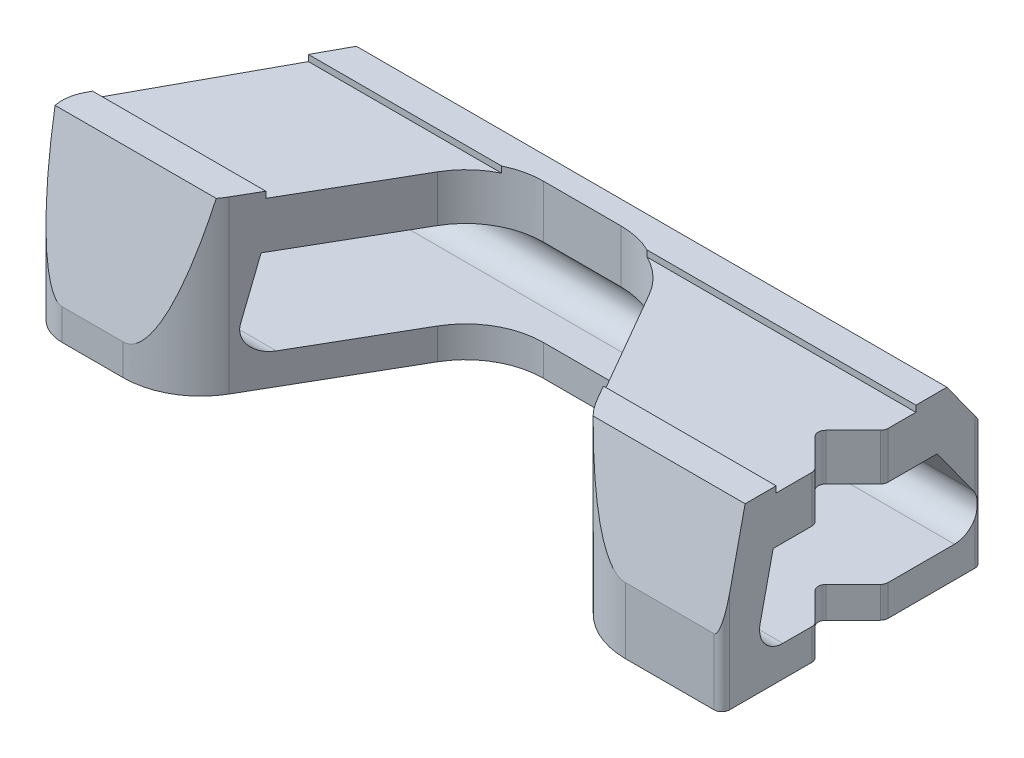
from build123d import *

# Parameters (mm, degrees)
SKETCH1_R               = 5
BOSS_EXTRUDE1_DEPTH     = 22
FILLET1_R               = 1
FILLET2_R               = 10
SKETCH3_W               = 18
SKETCH3_H               = 10
CUT_EXTRUDE2_DEPTH      = 45
CUT_EXTRUDE2_DEPTH_BACK = 46


with BuildPart() as part:
    # Sketch1 → Boss-Extrude1 (new body)
    with BuildSketch(Plane(origin=(0, 0, 0), x_dir=(1, 0, 0), z_dir=(0, 1, 0))):
        with BuildLine():
            Line((44, 17), (35, 26))
            Line((35, 26), (25, 26))
            Line((25, 26), (5, 20.641016151))
            Line((5, 20.641016151), (-15, 26))
            Line((-15, 26), (-25, 26))
            Line((-25, 26), (-44.391127187, -9.608765584))
            ThreePointArc((-44.391127187, -9.608765584), (-38.766232585, -7.154608585), (-35, -12))
            ThreePointArc((-35, -12), (-36.464466094, -15.535533906), (-40, -17))
            Line((-40, -17), (-26.36195996, -17))
            Line((-26.36195996, -17), (-13.660254038, 5))
            ThreePointArc((-13.660254038, 5), (-10, 8.660254038), (-5, 10))
            Line((-5, 10), (5, 10))
            ThreePointArc((5, 10), (10, 8.660254038), (13.660254038, 5))
            Line((13.660254038, 5), (25.784609691, -16))
            Line((25.784609691, -16), (44, -16))
            Line((44, -16), (44, -4))
            Line((44, -4), (39.5, 0.5))
            Line((39.5, 0.5), (44, 5))
            Line((44, 5), (44, 17))
        make_face()
        with Locations((-40, -12)):
            Circle(SKETCH1_R)
    extrude(amount=BOSS_EXTRUDE1_DEPTH)

    # Fillet1
    fillet1_edges = [part.edges().sort_by_distance(p)[0] for p in [
        (-25, 11, -26),
        (-15, 11, -26),
        (25, 11, -26),
        (35, 11, -26),
        (44, 11, -17),
        (44, 11, -5),
        (39.5, 11, -0.5),
        (44, 11, 4),
        (44, 11, 16),
    ]]
    fillet(fillet1_edges, radius=FILLET1_R)

    # Fillet2
    fillet2_edges = [part.edges().sort_by_distance(p)[0] for p in [
        (-26.36195996, 11, 17),
        (5, 11, -20.641016151),
        (25.784609691, 11, 16),
    ]]
    fillet(fillet2_edges, radius=FILLET2_R)

    # Sketch3 → Cut-Extrude2 (cut, two sides)
    with BuildSketch(Plane(origin=(0, 0, 0), x_dir=(0, 0, -1), z_dir=(1, 0, 0))) as cut_extrude2_sk:
        Polygon((-9, 22), (-9, 31.2), (-17, 31.2), (-17, 4), (-13, 22), align=None)
        with Locations((0, 26.2)):
            Rectangle(SKETCH3_W, SKETCH3_H)
        Polygon((26, 31.2), (9, 31.2), (9, 22), (13, 22), (26, 4), align=None)
        with BuildLine():
            Line((11.743443525, 15.2), (-9.389141968, 15.2))
            Line((-9.389141968, 15.2), (-11.066743885, 7.650791373))
            ThreePointArc((-11.066743885, 7.650791373), (-10.478308141, 5.122817819), (-8.138182705, 4))
            Line((-8.138182705, 4), (13.965065195, 4))
            ThreePointArc((13.965065195, 4), (16.636152519, 5.634242881), (16.39710288, 8.756471662))
            Line((16.39710288, 8.756471662), (11.743443525, 15.2))
        make_face()
    extrude(amount=CUT_EXTRUDE2_DEPTH, mode=Mode.SUBTRACT)
    extrude(cut_extrude2_sk.sketch, amount=-CUT_EXTRUDE2_DEPTH_BACK, mode=Mode.SUBTRACT)


solid = part.part
